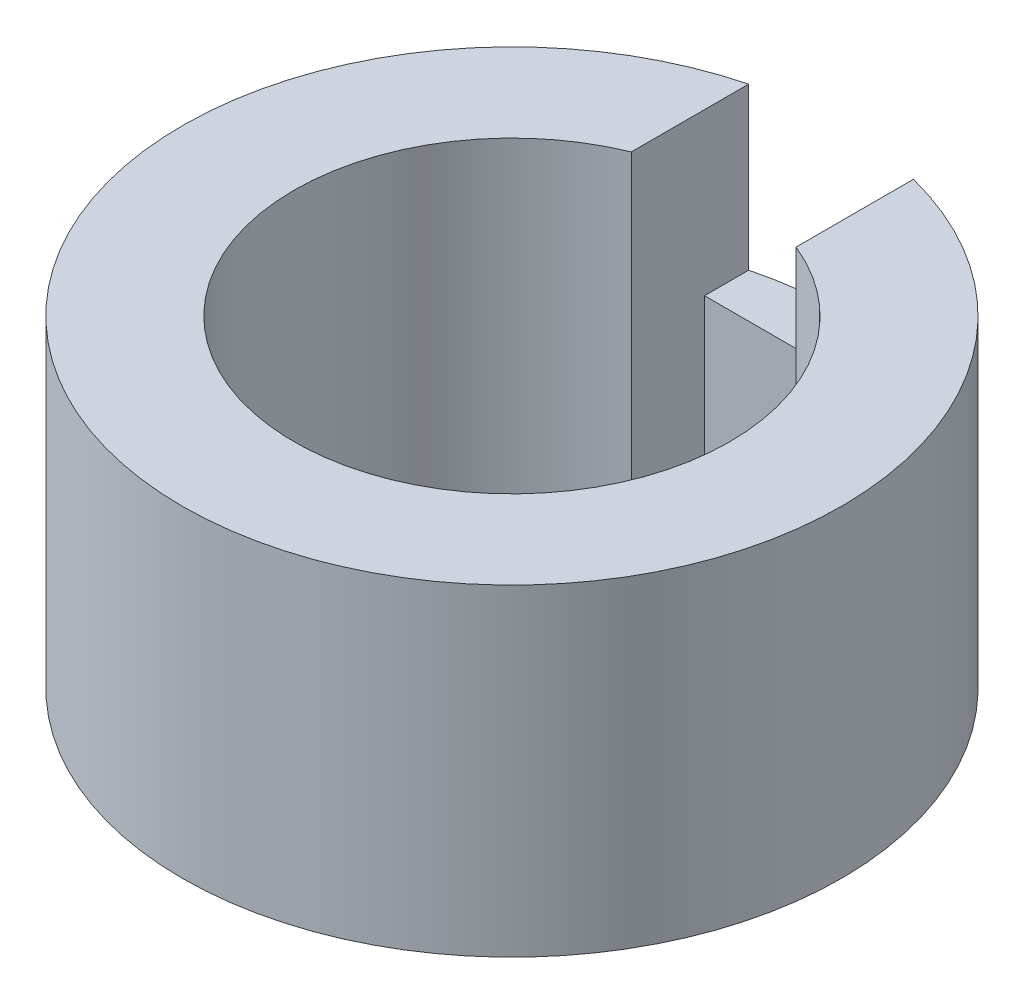
from build123d import *

# Parameters (mm, degrees)
SKETCH1_R           = 9
BOSS_EXTRUDE1_DEPTH = 8.8
SKETCH2_W           = 4.5
SKETCH2_H           = 4.4
CUT_EXTRUDE1_DEPTH  = 10


with BuildPart() as part:
    # Sketch1 → Boss-Extrude1 (new body)
    with BuildSketch(Plane(origin=(0, 0, 0), x_dir=(1, 0, 0), z_dir=(0, 1, 0))):
        Circle(SKETCH1_R)
        with BuildLine():
            ThreePointArc((5.95, 0), (-3.317755265, -4.939129478), (-2.25, 5.508175742))
            Line((-2.25, 5.508175742), (-2.25, 7.508175742))
            Line((-2.25, 7.508175742), (2.25, 7.508175742))
            Line((2.25, 7.508175742), (2.25, 5.508175742))
            ThreePointArc((2.25, 5.508175742), (4.939129478, 3.317755265), (5.95, 0))
        make_face(mode=Mode.SUBTRACT)
    extrude(amount=BOSS_EXTRUDE1_DEPTH)

    # Sketch2 → Cut-Extrude1 (cut, through all)
    with BuildSketch(Plane.XY):
        with Locations((0, 6.6)):
            Rectangle(SKETCH2_W, SKETCH2_H)
    extrude(amount=-CUT_EXTRUDE1_DEPTH, mode=Mode.SUBTRACT)


solid = part.part
